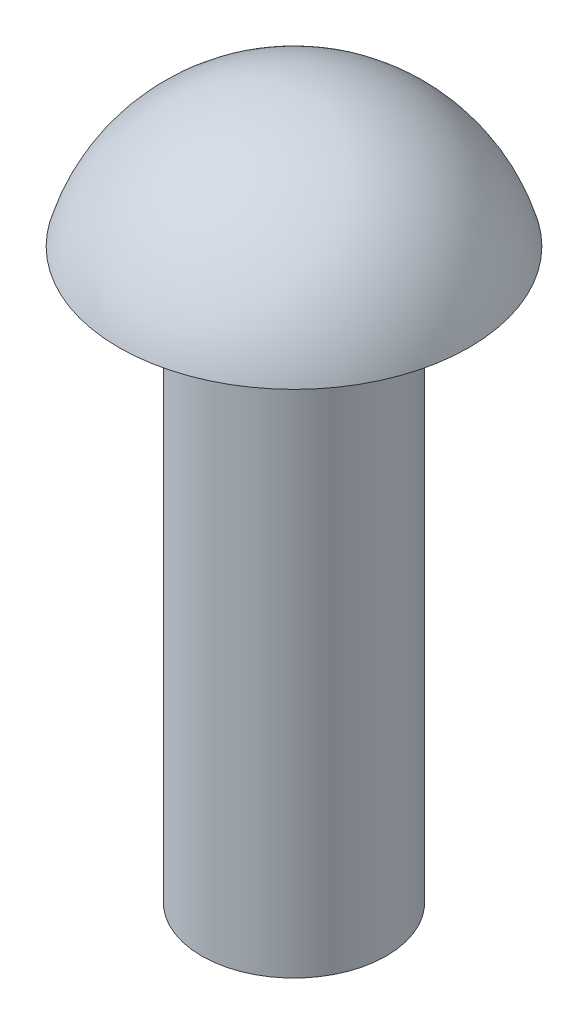
from build123d import *


with BuildPart() as part:
    # Sketch1 → Revolve2 (revolve)
    with BuildSketch(Plane(origin=(0, 0, 0), x_dir=(0, 0, -1), z_dir=(1, 0, 0))):
        with BuildLine():
            Line((0, -7.4), (0.975, -7.4))
            Line((0.975, -7.4), (0.975, -1.4))
            Line((0.975, -1.4), (1.85, -1.4))
            ThreePointArc((1.85, -1.4), (1.160010776, -0.389450046), (0, 0))
            Line((0, 0), (0, -7.4))
        make_face()
    revolve(axis=Axis((0, 0, 0), (0, -1, 0)))


solid = part.part
